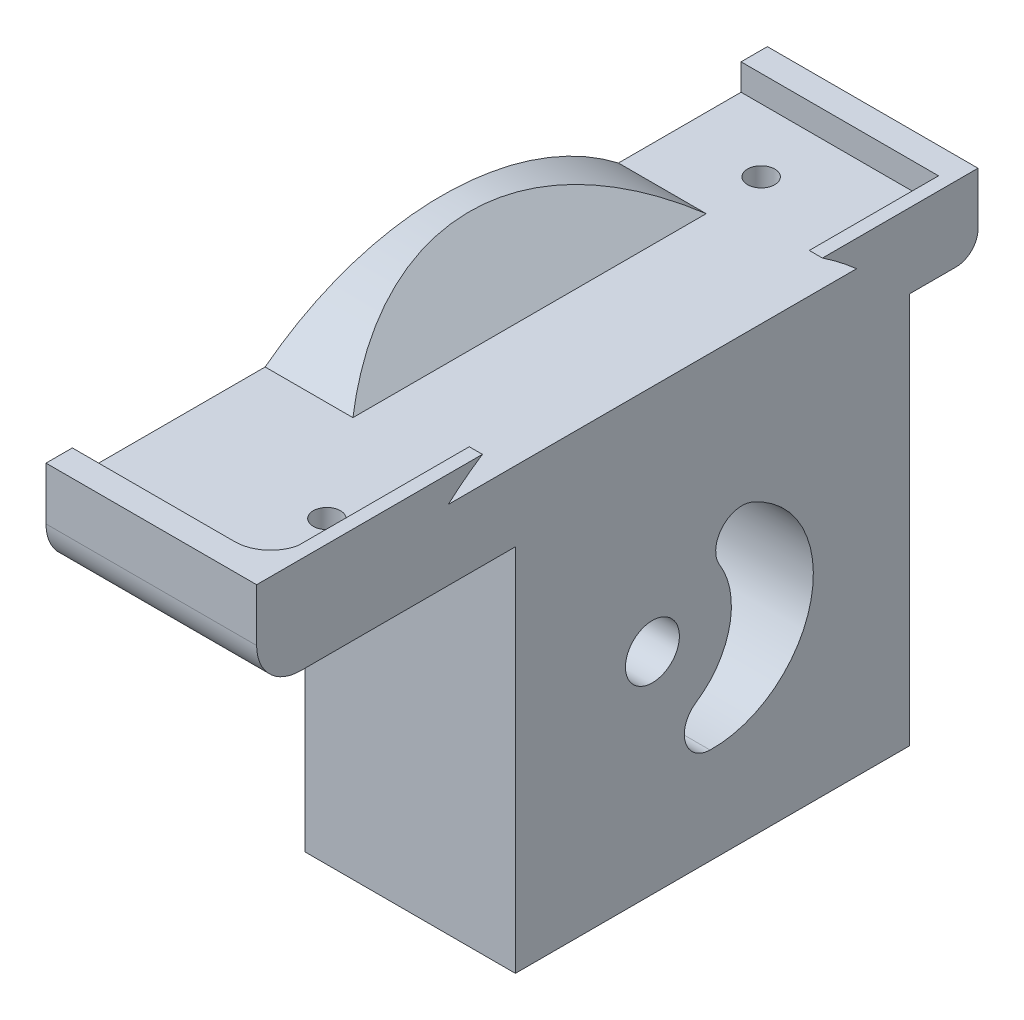
from build123d import *

# Parameters (mm, degrees)
SKETCH1_R           = 22.45
SKETCH1_R_2         = 6.11
SKETCH1_R_3         = 18.55
SKETCH1_R_4         = 5.25
SKETCH1_R_5         = 3.075
BOSS_EXTRUDE1_DEPTH = 5.5
SKETCH1_3_R         = 22.45
SKETCH1_3_R_2       = 6.11
SKETCH1_3_R_3       = 18.55
BOSS_EXTRUDE2_DEPTH = 6
BOSS_EXTRUDE3_START = -17
SKETCH1_4_R         = 18.55
BOSS_EXTRUDE3_DEPTH = 11
BOSS_EXTRUDE4_DEPTH = 10
DRAFT1_ANGLE        = 45
BOSS_EXTRUDE5_DEPTH = 3
SKETCH4_R           = 3.075
BOSS_EXTRUDE6_DEPTH = 1.5
CUT_EXTRUDE1_START  = -11
SKETCH3_4_R         = 1.55
CUT_EXTRUDE1_DEPTH  = 11
CUT_EXTRUDE2_START  = -9.6
SKETCH3_5_R         = 1.55
CUT_EXTRUDE2_DEPTH  = 2.6
CUT_EXTRUDE3_START  = -8
SKETCH3_6_R         = 1.55
CUT_EXTRUDE3_DEPTH  = 2.5
CUT_EXTRUDE4_DEPTH  = 13


with BuildPart() as part:
    # Sketch1 → Boss-Extrude1 (new body)
    with BuildSketch(Plane(origin=(170.865454796, 0, 0), x_dir=(0, 0, -1), z_dir=(1, 0, 0))):
        with BuildLine():
            ThreePointArc((-69.739907234, -12.350878767), (-85.614454471, -5.775426005), (-92.189907234, 10.099121233))
            Line((-92.189907234, 10.099121233), (-92.189907234, -12.350878767))
            Line((-92.189907234, -12.350878767), (-69.739907234, -12.350878767))
        make_face()
        with BuildLine():
            Line((-116.677399291, 29.749121233), (-92.189907234, 29.749121233))
            Line((-92.189907234, 29.749121233), (-92.189907234, 10.099121233))
            ThreePointArc((-92.189907234, 10.099121233), (-69.739907234, 32.549121233), (-47.289907234, 10.099121233))
            Line((-47.289907234, 10.099121233), (-47.289907234, 32.249121233))
            Line((-47.289907234, 32.249121233), (-41.977399291, 32.249121233))
            ThreePointArc((-41.977399291, 32.249121233), (-40.209632338, 32.98135428), (-39.477399291, 34.749121233))
            Line((-39.477399291, 34.749121233), (-39.477399291, 40.749121233))
            Line((-39.477399291, 40.749121233), (-42.477399291, 40.749121233))
            Line((-42.477399291, 40.749121233), (-42.477399291, 37.749121233))
            Line((-42.477399291, 37.749121233), (-118.677399291, 37.749121233))
            Line((-118.677399291, 37.749121233), (-118.677399291, 40.749121233))
            Line((-118.677399291, 40.749121233), (-121.677399291, 40.749121233))
            Line((-121.677399291, 40.749121233), (-121.677399291, 34.749121233))
            ThreePointArc((-121.677399291, 34.749121233), (-120.212933197, 31.213587327), (-116.677399291, 29.749121233))
        make_face()
        with BuildLine():
            Line((-47.289907234, -12.350878767), (-47.289907234, 10.099121233))
            ThreePointArc((-47.289907234, 10.099121233), (-53.865359996, -5.775426005), (-69.739907234, -12.350878767))
            Line((-69.739907234, -12.350878767), (-47.289907234, -12.350878767))
        make_face()
        with Locations((-69.739907234, 10.099121233)):
            Circle(SKETCH1_R)
        with Locations((-76.577399291, 11.598688626)):
            Circle(SKETCH1_R_2, mode=Mode.SUBTRACT)
        with Locations((-69.739907234, 10.099121233)):
            Circle(SKETCH1_R_3)
        with Locations((-76.577399291, 11.598688626)):
            Circle(SKETCH1_R_2, mode=Mode.SUBTRACT)
        with Locations((-76.577399291, 11.598688626)):
            Circle(SKETCH1_R_2)
        with Locations((-76.577399291, 11.598688626)):
            Circle(SKETCH1_R_4, mode=Mode.SUBTRACT)
        with Locations((-76.577399291, 11.598688626)):
            Circle(SKETCH1_R_4)
        with Locations((-76.577399291, 11.598688626)):
            Circle(SKETCH1_R_5, mode=Mode.SUBTRACT)
    extrude(amount=BOSS_EXTRUDE1_DEPTH)

    # Sketch1_3 → Boss-Extrude2 (add)
    with BuildSketch(Plane(origin=(170.865454796, 0, 0), x_dir=(0, 0, -1), z_dir=(1, 0, 0))):
        with BuildLine():
            ThreePointArc((-69.739907234, -12.350878767), (-85.614454471, -5.775426005), (-92.189907234, 10.099121233))
            Line((-92.189907234, 10.099121233), (-92.189907234, -12.350878767))
            Line((-92.189907234, -12.350878767), (-69.739907234, -12.350878767))
        make_face()
        with BuildLine():
            Line((-47.289907234, -12.350878767), (-47.289907234, 10.099121233))
            ThreePointArc((-47.289907234, 10.099121233), (-53.865359996, -5.775426005), (-69.739907234, -12.350878767))
            Line((-69.739907234, -12.350878767), (-47.289907234, -12.350878767))
        make_face()
        with BuildLine():
            Line((-116.677399291, 29.749121233), (-92.189907234, 29.749121233))
            Line((-92.189907234, 29.749121233), (-92.189907234, 10.099121233))
            ThreePointArc((-92.189907234, 10.099121233), (-69.739907234, 32.549121233), (-47.289907234, 10.099121233))
            Line((-47.289907234, 10.099121233), (-47.289907234, 32.249121233))
            Line((-47.289907234, 32.249121233), (-41.977399291, 32.249121233))
            ThreePointArc((-41.977399291, 32.249121233), (-40.209632338, 32.98135428), (-39.477399291, 34.749121233))
            Line((-39.477399291, 34.749121233), (-39.477399291, 40.749121233))
            Line((-39.477399291, 40.749121233), (-42.477399291, 40.749121233))
            Line((-42.477399291, 40.749121233), (-42.477399291, 37.749121233))
            Line((-42.477399291, 37.749121233), (-118.677399291, 37.749121233))
            Line((-118.677399291, 37.749121233), (-118.677399291, 40.749121233))
            Line((-118.677399291, 40.749121233), (-121.677399291, 40.749121233))
            Line((-121.677399291, 40.749121233), (-121.677399291, 34.749121233))
            ThreePointArc((-121.677399291, 34.749121233), (-120.212933197, 31.213587327), (-116.677399291, 29.749121233))
        make_face()
        with Locations((-69.739907234, 10.099121233)):
            Circle(SKETCH1_3_R)
        with Locations((-76.577399291, 11.598688626)):
            Circle(SKETCH1_3_R_2, mode=Mode.SUBTRACT)
        with Locations((-69.739907234, 10.099121233)):
            Circle(SKETCH1_3_R_3)
        with Locations((-76.577399291, 11.598688626)):
            Circle(SKETCH1_3_R_2, mode=Mode.SUBTRACT)
    extrude(amount=-BOSS_EXTRUDE2_DEPTH)

    # Sketch1_4 → Boss-Extrude3 (add)
    with BuildSketch(Plane(origin=(170.865454796, 0, 0), x_dir=(0, 0, -1), z_dir=(1, 0, 0)).offset(BOSS_EXTRUDE3_START)):
        with BuildLine():
            Line((-116.677399291, 29.749121233), (-92.189907234, 29.749121233))
            Line((-92.189907234, 29.749121233), (-92.189907234, -12.350878767))
            Line((-92.189907234, -12.350878767), (-47.289907234, -12.350878767))
            Line((-47.289907234, -12.350878767), (-47.289907234, 32.249121233))
            Line((-47.289907234, 32.249121233), (-41.977399291, 32.249121233))
            ThreePointArc((-41.977399291, 32.249121233), (-40.209632338, 32.98135428), (-39.477399291, 34.749121233))
            Line((-39.477399291, 34.749121233), (-39.477399291, 40.749121233))
            Line((-39.477399291, 40.749121233), (-42.477399291, 40.749121233))
            Line((-42.477399291, 40.749121233), (-42.477399291, 37.749121233))
            Line((-42.477399291, 37.749121233), (-118.677399291, 37.749121233))
            Line((-118.677399291, 37.749121233), (-118.677399291, 40.749121233))
            Line((-118.677399291, 40.749121233), (-121.677399291, 40.749121233))
            Line((-121.677399291, 40.749121233), (-121.677399291, 34.749121233))
            ThreePointArc((-121.677399291, 34.749121233), (-120.212933197, 31.213587327), (-116.677399291, 29.749121233))
        make_face()
        with Locations((-69.739907234, 10.099121233)):
            Circle(SKETCH1_4_R, mode=Mode.SUBTRACT)
    extrude(amount=BOSS_EXTRUDE3_DEPTH)

    # Sketch2 → Boss-Extrude4 (add)
    with BuildSketch(Plane.ZY.offset(-153.865454796)):
        with BuildLine():
            Line((56.448939974, 37.749121233), (96.705858608, 37.749121233))
            ThreePointArc((96.705858608, 37.749121233), (76.577399291, 44.598688626), (56.448939974, 37.749121233))
        make_face()
    extrude(amount=-BOSS_EXTRUDE4_DEPTH)

    # Draft1
    draft1_faces = [part.faces().sort_by_distance(p)[0] for p in [
        (163.865454796, 40.514883149, 76.577399291),
    ]]
    draft(draft1_faces, Plane(origin=(274.224792623, 37.749121233, 0), x_dir=(1, 0, 0), z_dir=(0, 1, 0)), DRAFT1_ANGLE)

    # Sketch3 → Boss-Extrude5 (add)
    with BuildSketch(Plane(origin=(0, 37.749121233, 0), x_dir=(1, 0, 0), z_dir=(0, 1, 0))):
        with BuildLine():
            Line((176.365454796, -118.677399291), (176.365454796, -115.477399292))
            ThreePointArc((176.365454796, -115.477399292), (174.926704491, -117.77896141), (172.365454796, -118.677399291))
            Line((172.365454796, -118.677399291), (176.365454796, -118.677399291))
        make_face()
    extrude(amount=BOSS_EXTRUDE5_DEPTH)

    # Sketch4 → Boss-Extrude6 (add)
    with BuildSketch(Plane(origin=(176.365454796, 0, 0), x_dir=(0, 0, -1), z_dir=(1, 0, 0))):
        with BuildLine():
            Line((-115.477399292, 37.749121233), (-115.477399292, 40.749121233))
            Line((-115.477399292, 40.749121233), (-121.677399291, 40.749121233))
            Line((-121.677399291, 40.749121233), (-121.677399291, 34.749121233))
            ThreePointArc((-121.677399291, 34.749121233), (-120.212933197, 31.213587327), (-116.677399291, 29.749121233))
            Line((-116.677399291, 29.749121233), (-92.189907234, 29.749121233))
            Line((-92.189907234, 29.749121233), (-92.189907234, -12.350878767))
            Line((-92.189907234, -12.350878767), (-47.289907234, -12.350878767))
            Line((-47.289907234, -12.350878767), (-47.289907234, 32.249121233))
            Line((-47.289907234, 32.249121233), (-41.977399291, 32.249121233))
            ThreePointArc((-41.977399291, 32.249121233), (-40.209632338, 32.98135428), (-39.477399291, 34.749121233))
            Line((-39.477399291, 34.749121233), (-39.477399291, 40.749121233))
            Line((-39.477399291, 40.749121233), (-42.477399291, 40.749121233))
            Line((-42.477399291, 40.749121233), (-42.477399291, 37.749121233))
            Line((-42.477399291, 37.749121233), (-53.314663543, 37.749121233))
            Line((-53.314663543, 37.749121233), (-99.840135039, 37.749121233))
            Line((-99.840135039, 37.749121233), (-115.477399292, 37.749121233))
        make_face()
        with Locations((-76.577399291, 11.598688626)):
            Circle(SKETCH4_R, mode=Mode.SUBTRACT)
        with BuildLine():
            Line((-95.948828739, 40.749121233), (-115.477399292, 40.749121233))
            Line((-115.477399292, 40.749121233), (-115.477399292, 37.749121233))
            Line((-115.477399292, 37.749121233), (-99.840135039, 37.749121233))
            ThreePointArc((-99.840135039, 37.749121233), (-97.9471913, 39.31749072), (-95.948828739, 40.749121233))
        make_face()
        with BuildLine():
            ThreePointArc((-57.205969843, 40.749121233), (-55.207607282, 39.31749072), (-53.314663543, 37.749121233))
            Line((-53.314663543, 37.749121233), (-42.477399291, 37.749121233))
            Line((-42.477399291, 37.749121233), (-42.477399291, 40.749121233))
            Line((-42.477399291, 40.749121233), (-57.205969843, 40.749121233))
        make_face()
    extrude(amount=BOSS_EXTRUDE6_DEPTH)

    # Sketch3_4 → Cut-Extrude1 (cut)
    with BuildSketch(Plane(origin=(0, 37.749121233, 0), x_dir=(1, 0, 0), z_dir=(0, 1, 0)).offset(CUT_EXTRUDE1_START)):
        with Locations(Location((172.340454796, -108.144978953, 0), (0, 0, 180))):
            Circle(SKETCH3_4_R)
        with Locations(Location((163.365454796, -49.683845424, 0), (0, 0, 180))):
            Circle(SKETCH3_4_R)
    extrude(amount=CUT_EXTRUDE1_DEPTH, mode=Mode.SUBTRACT)

    # Sketch3_5 → Cut-Extrude2 (cut)
    with BuildSketch(Plane(origin=(0, 37.749121233, 0), x_dir=(1, 0, 0), z_dir=(0, 1, 0)).offset(CUT_EXTRUDE2_START)):
        Polygon((164.91903222, -47.289907234), (161.811877372, -47.289907234), (160.515454796, -48.038397157), (160.515454796, -51.329293692), (163.365454796, -52.974741959), (166.215454796, -51.329293692), (166.215454796, -48.038397157), align=None)
        with Locations(Location((163.365454796, -49.683845424, 0), (0, 0, 180))):
            Circle(SKETCH3_5_R, mode=Mode.SUBTRACT)
        Polygon((166.215454796, -47.289907234), (164.91903222, -47.289907234), (166.215454796, -48.038397157), align=None)
        Polygon((160.515454796, -48.038397157), (161.811877372, -47.289907234), (160.515454796, -47.289907234), align=None)
    extrude(amount=CUT_EXTRUDE2_DEPTH, mode=Mode.SUBTRACT)

    # Sketch3_6 → Cut-Extrude3 (cut)
    with BuildSketch(Plane(origin=(0, 37.749121233, 0), x_dir=(1, 0, 0), z_dir=(0, 1, 0)).offset(CUT_EXTRUDE3_START)):
        Polygon((170.695006529, -110.994978953), (173.985903063, -110.994978953), (175.63135133, -108.144978953), (173.985903063, -105.294978953), (170.695006529, -105.294978953), (169.049558261, -108.144978953), align=None)
        with Locations(Location((172.340454796, -108.144978953, 0), (0, 0, 180))):
            Circle(SKETCH3_6_R, mode=Mode.SUBTRACT)
    extrude(amount=CUT_EXTRUDE3_DEPTH, mode=Mode.SUBTRACT)

    # Sketch5 → Cut-Extrude4 (cut)
    with BuildSketch(Plane(origin=(177.865454796, 0, 0), x_dir=(0, 0, -1), z_dir=(1, 0, 0))):
        with BuildLine():
            ThreePointArc((-65.174281564, 20.653980883), (-58.506884568, 7.635546229), (-70.01055365, -1.397693566))
            ThreePointArc((-70.01055365, -1.397693566), (-72.822049276, 0.768705961), (-71.5993125, 4.100778791))
            ThreePointArc((-71.5993125, 4.100778791), (-67.786338075, 9.670673406), (-68.918335583, 16.325076583))
            ThreePointArc((-68.918335583, 16.325076583), (-68.634368389, 19.863036052), (-65.174281564, 20.653980883))
        make_face()
    extrude(amount=-CUT_EXTRUDE4_DEPTH, mode=Mode.SUBTRACT)


solid = part.part
